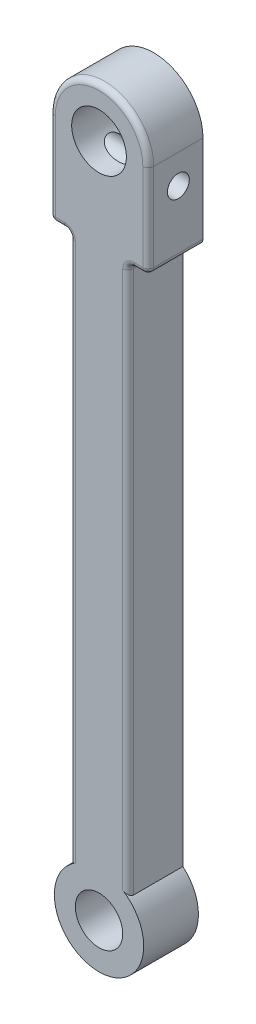
from build123d import *

# Parameters (mm, degrees)
SKETCH1_R           = 6.5
SKETCH1_R_2         = 7.5
BOSS_EXTRUDE1_DEPTH = 15
FILLET2_R           = 1.5
SKETCH4_R           = 3
CUT_EXTRUDE1_DEPTH  = 28


with BuildPart() as part:
    # Sketch1 → Boss-Extrude1 (new body)
    with BuildSketch(Plane.XY):
        with BuildLine():
            Line((-13.5, 0), (-13.5, -24))
            ThreePointArc((-13.5, -24), (-13.060660172, -25.060660172), (-12, -25.5))
            Line((-12, -25.5), (-9.5, -25.5))
            ThreePointArc((-9.5, -25.5), (-8.439339828, -25.939339828), (-8, -27))
            Line((-8, -27), (-8, -175.723012342))
            ThreePointArc((-8, -175.723012342), (0, -197.25), (8, -175.723012342))
            Line((8, -175.723012342), (8, -27))
            ThreePointArc((8, -27), (8.439339828, -25.939339828), (9.5, -25.5))
            Line((9.5, -25.5), (12, -25.5))
            ThreePointArc((12, -25.5), (13.060660172, -25.060660172), (13.5, -24))
            Line((13.5, -24), (13.5, 0))
            ThreePointArc((13.5, 0), (0, 13.5), (-13.5, 0))
        make_face()
        with Locations((0, -185)):
            Circle(SKETCH1_R, mode=Mode.SUBTRACT)
        Circle(SKETCH1_R_2, mode=Mode.SUBTRACT)
    extrude(amount=BOSS_EXTRUDE1_DEPTH)

    # Fillet2
    fillet2_edges = [part.edges().sort_by_distance(p)[0] for p in [
        (-13.060660172, -25.060660172, 15),
        (-10.75, -25.5, 15),
        (-8.439339828, -25.939339828, 15),
        (-8, -101.361506171, 15),
        (8, -101.361506171, 15),
        (8.439339828, -25.939339828, 15),
        (10.75, -25.5, 15),
        (13.060660172, -25.060660172, 15),
        (13.5, -12, 15),
        (0, 13.5, 15),
        (-13.5, -12, 15),
    ]]
    fillet(fillet2_edges, radius=FILLET2_R)

    # Sketch4 → Cut-Extrude1 (cut, through all)
    with BuildSketch(Plane(origin=(13.5, 0, 0), x_dir=(0, 0, -1), z_dir=(1, 0, 0))):
        with Locations((-6.75, -8)):
            Circle(SKETCH4_R)
    extrude(amount=-CUT_EXTRUDE1_DEPTH, mode=Mode.SUBTRACT)


solid = part.part
